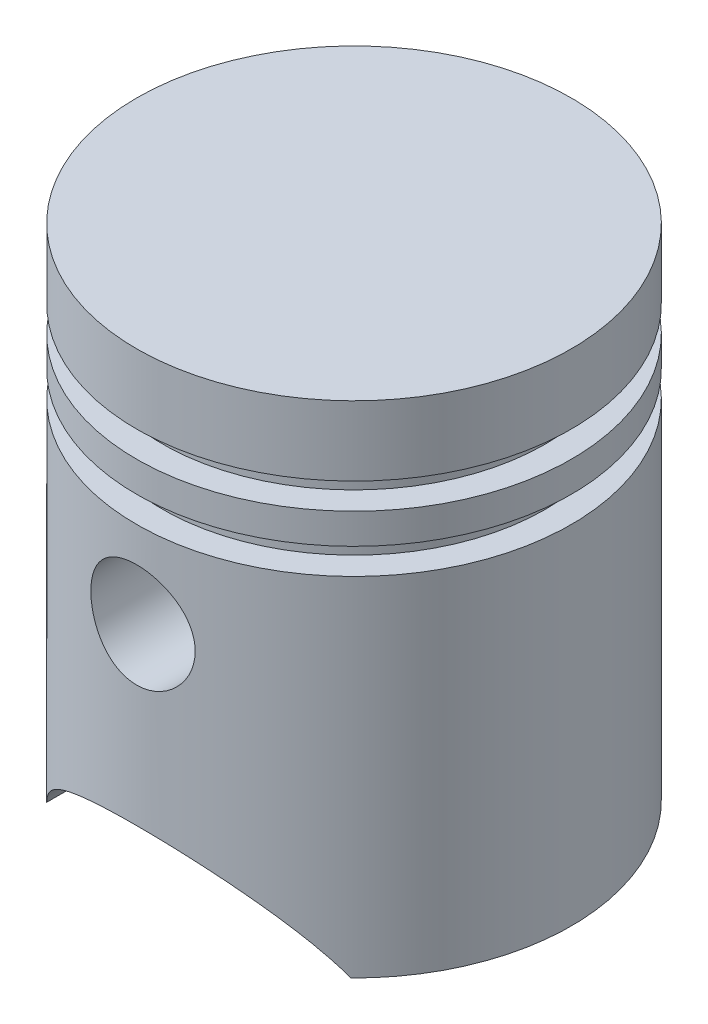
from build123d import *

# Parameters (mm, degrees)
CUT_EXTRUDE1_DEPTH  = 31.5
SKETCH3_R           = 6
CUT_EXTRUDE2_DEPTH  = 31.5
SKETCH4_R           = 7.5
SKETCH4_R_2         = 6
BOSS_EXTRUDE1_DEPTH = 13


with BuildPart() as part:
    # Sketch1 → Revolve1 (revolve)
    with BuildSketch(Plane.XY):
        Polygon((23, 0), (25, 0), (25, 40), (22, 40), (22, 43), (25, 43), (25, 46.5), (22, 46.5), (22, 49.5), (25, 49.5), (25, 57.5), (0, 57.5), (0, 56.203662834), (23, 56.203662834), (23, 51.5), (20, 51.5), (20, 44.75), (20, 38), (23, 38), align=None)
    revolve(axis=Axis((0, 63, 0), (0, -1, 0)))

    # Sketch2 → Cut-Extrude1 (cut, symmetric)
    with BuildSketch(Plane.XY):
        with BuildLine():
            Line((-17.5, 0), (17.5, 0))
            ThreePointArc((17.5, 0), (0, 10), (-17.5, 0))
        make_face()
    extrude(amount=CUT_EXTRUDE1_DEPTH, both=True, mode=Mode.SUBTRACT)

    # Sketch3 → Cut-Extrude2 (cut, symmetric)
    with BuildSketch(Plane.XY):
        with Locations((0, 30)):
            Circle(SKETCH3_R)
    extrude(amount=CUT_EXTRUDE2_DEPTH, both=True, mode=Mode.SUBTRACT)

    # Sketch4 → Boss-Extrude1 (add)
    with BuildSketch(Plane.XY.offset(10)):
        with Locations((0, 30)):
            Circle(SKETCH4_R)
        with Locations((0, 30)):
            Circle(SKETCH4_R_2, mode=Mode.SUBTRACT)
    boss_extrude1 = extrude(amount=BOSS_EXTRUDE1_DEPTH)

    # Mirror1: Boss-Extrude1 across plane
    add(boss_extrude1.mirror(Plane.XY))


solid = part.part
